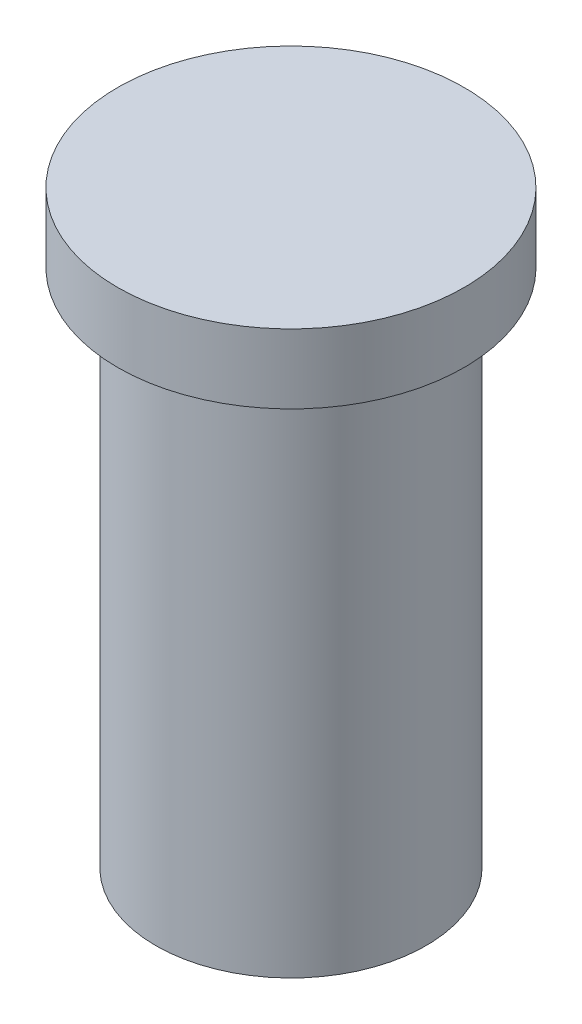
from build123d import *

# Parameters (mm, degrees)
SKETCH1_R           = 3.9
BOSS_EXTRUDE1_DEPTH = 15
SKETCH2_R           = 5
BOSS_EXTRUDE2_DEPTH = 2


with BuildPart() as part:
    # Sketch1 → Boss-Extrude1 (new body)
    with BuildSketch(Plane(origin=(0, 0, 0), x_dir=(1, 0, 0), z_dir=(0, 1, 0))):
        Circle(SKETCH1_R)
    extrude(amount=BOSS_EXTRUDE1_DEPTH)

    # Sketch2 → Boss-Extrude2 (add)
    with BuildSketch(Plane(origin=(0, 15, 0), x_dir=(1, 0, 0), z_dir=(0, 1, 0))):
        Circle(SKETCH2_R)
    extrude(amount=BOSS_EXTRUDE2_DEPTH)


solid = part.part
